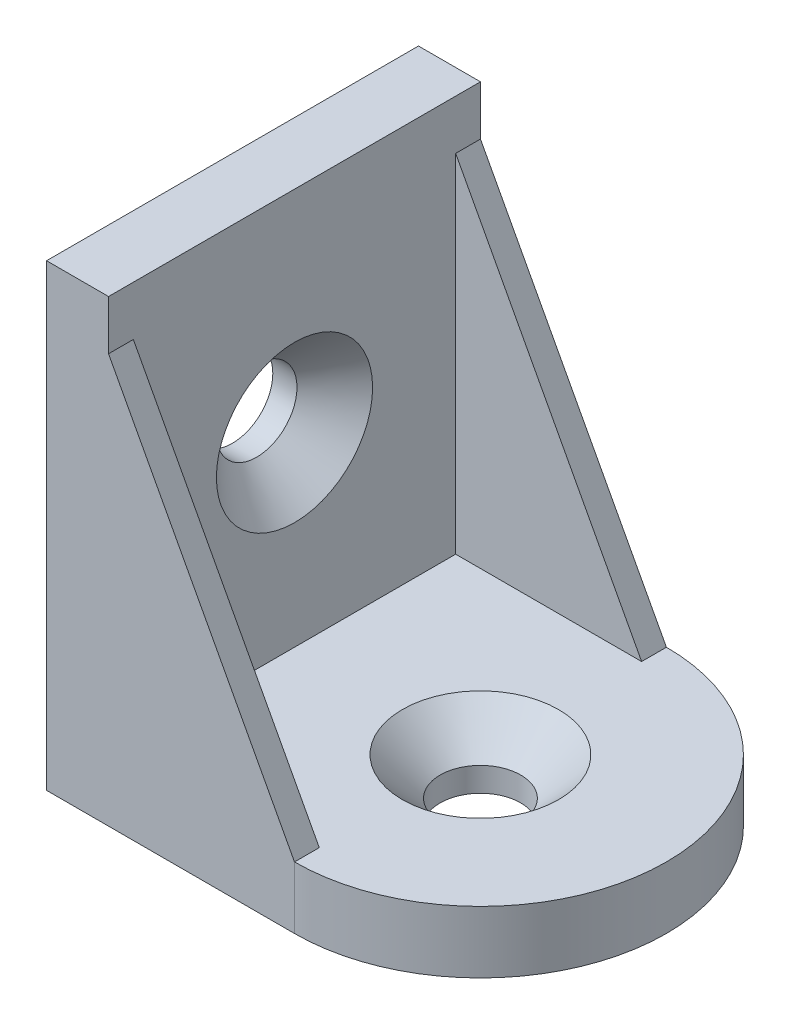
from build123d import *

# Parameters (mm, degrees)
EXTRUDE_1_DEPTH     = 15
CUT_EXTRUDE_2_DEPTH = 6
EXTRUDE_2_DEPTH     = 2


with BuildPart() as part:
    # Эскиз1 → Бобышка-Вытянуть1 (new body, symmetric)
    with BuildSketch(Plane.XY):
        Polygon((0, 37), (0, 0), (35, 0), (35, 5), (5, 5), (5, 37), align=None)
    extrude(amount=EXTRUDE_1_DEPTH, both=True)

    # Эскиз5 → Вырез-Вытянуть2 (cut, through all)
    with BuildSketch(Plane(origin=(0, 5, 0), x_dir=(1, 0, 0), z_dir=(0, 1, 0))):
        with BuildLine():
            Line((35, 15), (20, 15))
            ThreePointArc((20, 15), (30.606601718, 10.606601718), (35, 0))
            Line((35, 0), (35, 15))
        make_face()
        with BuildLine():
            Line((35, -15), (35, 0))
            ThreePointArc((35, 0), (30.606601718, -10.606601718), (20, -15))
            Line((20, -15), (35, -15))
        make_face()
    extrude(amount=-CUT_EXTRUDE_2_DEPTH, mode=Mode.SUBTRACT)

    # Эскиз2 → Бобышка-Вытянуть2 (add)
    with BuildSketch(Plane.XY.offset(15)):
        Polygon((5, 33), (20, 5), (5, 5), align=None)
    extrude_2 = extrude(amount=-EXTRUDE_2_DEPTH)

    # Зеркальное отражение2: Бобышка-Вытянуть2 across plane
    add(extrude_2.mirror(Plane.XY))

    # Эскиз8 → Зенковка для винта с полупотайной головкой M61 (revolve, cut)
    with BuildSketch(Plane(origin=(20, 5, 0), x_dir=(0, 0, 1), z_dir=(1, 0, 0))):
        Polygon((0, 0), (0, 11.202797012), (3.25, 9.25), (3.25, 3.05), (6.3, 0), align=None)
    hole_wizard_m61 = revolve(axis=Axis((20, 11.35, 0), (0, -1, 0)), mode=Mode.SUBTRACT)

    # Зеркальное отражение3: Зенковка для винта с полупотайной головкой M61 across plane
    add(hole_wizard_m61.mirror(Plane(origin=(0, 0, 0), x_dir=(0, 0, 1), z_dir=(-0.707106781, 0.707106781, 0))), mode=Mode.SUBTRACT)


solid = part.part
